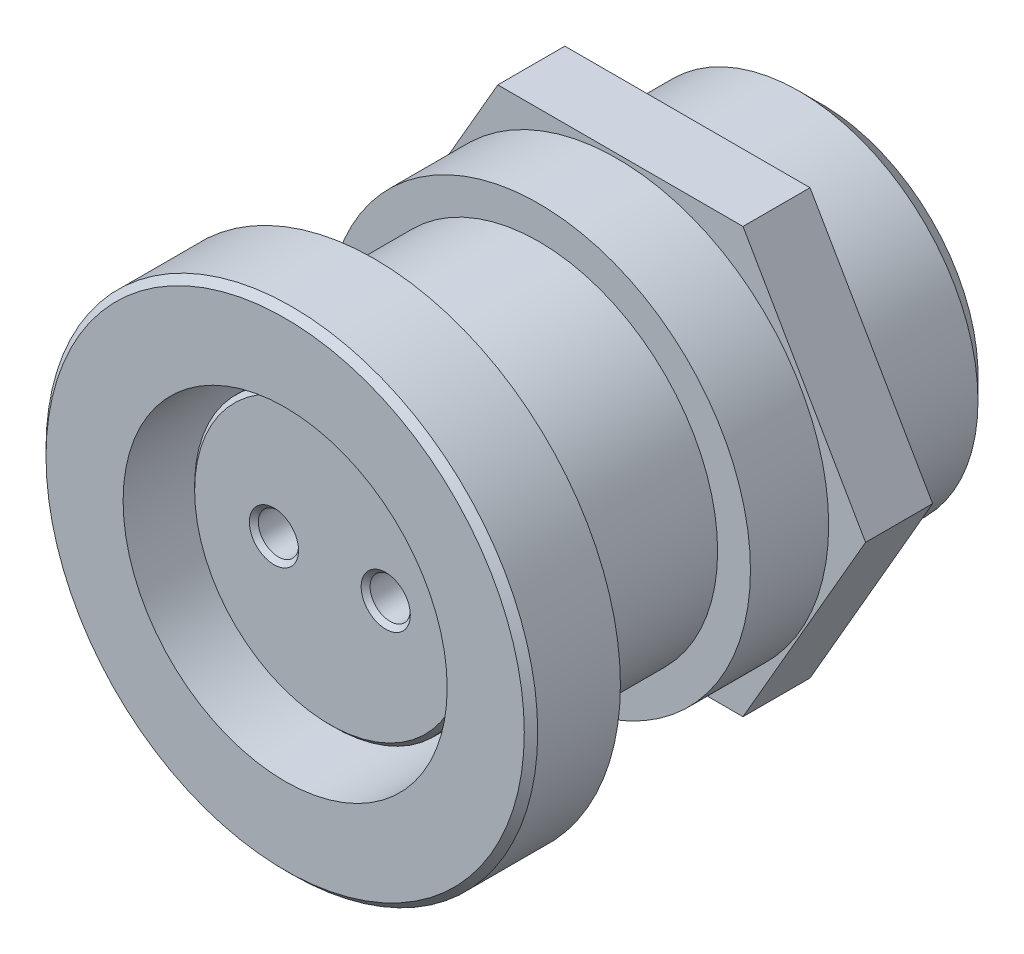
from build123d import *

# Parameters (mm, degrees)
SKETCH1_R          = 11
EXTRUDE1_DEPTH     = 4
SKETCH3_R          = 8
EXTRUDE3_DEPTH     = 20
SKETCH7_R          = 7.25
CUT_EXTRUDE5_DEPTH = 16
SKETCH4_R          = 6.25
EXTRUDE4_DEPTH     = 14
CHAMFER1_SIZE      = 0.2
CHAMFER3_SIZE      = 0.3
SKETCH5_R          = 10
SKETCH5_R_2        = 8.25
CUT_EXTRUDE1_DEPTH = 1.5
SKETCH6_R          = 0.9
CUT_EXTRUDE2_DEPTH = 5
CHAMFER4_SIZE      = 0.2
SKETCH8_R          = 6
CUT_EXTRUDE6_DEPTH = 2
CHAMFER5_SIZE      = 1
EXTRUDE6_START     = 7.35
SKETCH10_R         = 9.469128054
SKETCH10_R_2       = 8
EXTRUDE6_DEPTH     = 3.5
EXTRUDE5_START     = -7
EXTRUDE5_DEPTH     = 3


with BuildPart() as part:
    # Sketch1 → Extrude1 (new body)
    with BuildSketch(Plane.XY):
        Circle(SKETCH1_R)
    extrude(amount=EXTRUDE1_DEPTH)

    # Sketch3 → Extrude3 (add)
    with BuildSketch(Plane(origin=(0, 0, 0), x_dir=(-1, 0, 0), z_dir=(0, 0, -1))):
        Circle(SKETCH3_R)
    extrude(amount=EXTRUDE3_DEPTH)

    # Sketch7 → Cut-Extrude5 (cut)
    with BuildSketch(Plane.XY.offset(4)):
        Circle(SKETCH7_R)
    extrude(amount=-CUT_EXTRUDE5_DEPTH, mode=Mode.SUBTRACT)

    # Sketch4 → Extrude4 (add)
    with BuildSketch(Plane.XY.offset(-12)):
        Circle(SKETCH4_R)
    extrude(amount=EXTRUDE4_DEPTH)

    # Chamfer1
    chamfer1_edges = [part.edges().sort_by_distance(p)[0] for p in [
        (-6.25, 0, 2),
    ]]
    chamfer(chamfer1_edges, length=CHAMFER1_SIZE)

    # Chamfer3
    chamfer3_edges = [part.edges().sort_by_distance(p)[0] for p in [
        (-11, 0, 4),
    ]]
    chamfer(chamfer3_edges, length=CHAMFER3_SIZE)

    # Sketch5 → Cut-Extrude1 (cut)
    with BuildSketch(Plane(origin=(0, 0, 0), x_dir=(-1, 0, 0), z_dir=(0, 0, -1))):
        Circle(SKETCH5_R)
        Circle(SKETCH5_R_2, mode=Mode.SUBTRACT)
    extrude(amount=-CUT_EXTRUDE1_DEPTH, mode=Mode.SUBTRACT)

    # Sketch6 → Cut-Extrude2 (cut)
    with BuildSketch(Plane.XY.offset(2)):
        with Locations((2.5, 0)):
            Circle(SKETCH6_R)
        with Locations((-2.5, 0)):
            Circle(SKETCH6_R)
    extrude(amount=-CUT_EXTRUDE2_DEPTH, mode=Mode.SUBTRACT)

    # Chamfer4
    chamfer4_edges = [part.edges().sort_by_distance(p)[0] for p in [
        (1.6, 0, 2),
        (-3.4, 0, 2),
    ]]
    chamfer(chamfer4_edges, length=CHAMFER4_SIZE)

    # Sketch8 → Cut-Extrude6 (cut)
    with BuildSketch(Plane(origin=(0, 0, -20), x_dir=(-1, 0, 0), z_dir=(0, 0, -1))):
        Circle(SKETCH8_R)
    extrude(amount=-CUT_EXTRUDE6_DEPTH, mode=Mode.SUBTRACT)

    # Chamfer5
    chamfer5_edges = [part.edges().sort_by_distance(p)[0] for p in [
        (8, 0, -20),
    ]]
    chamfer(chamfer5_edges, length=CHAMFER5_SIZE)

    # Sketch10 → Extrude6 (add)
    with BuildSketch(Plane(origin=(0, 0, 0), x_dir=(-1, 0, 0), z_dir=(0, 0, -1)).offset(EXTRUDE6_START)):
        Circle(SKETCH10_R)
        Circle(SKETCH10_R_2, mode=Mode.SUBTRACT)
    extrude(amount=EXTRUDE6_DEPTH)

    # Sketch9 → Extrude5 (add)
    with BuildSketch(Plane(origin=(0, 0, -18), x_dir=(-1, 0, 0), z_dir=(0, 0, -1)).offset(EXTRUDE5_START)):
        Polygon((-5.484827557, 9.5), (5.484827557, 9.5), (10.969655115, 0), (5.484827557, -9.5), (-5.484827557, -9.5), (-10.969655115, 0), align=None)
    extrude(amount=EXTRUDE5_DEPTH)


solid = part.part
